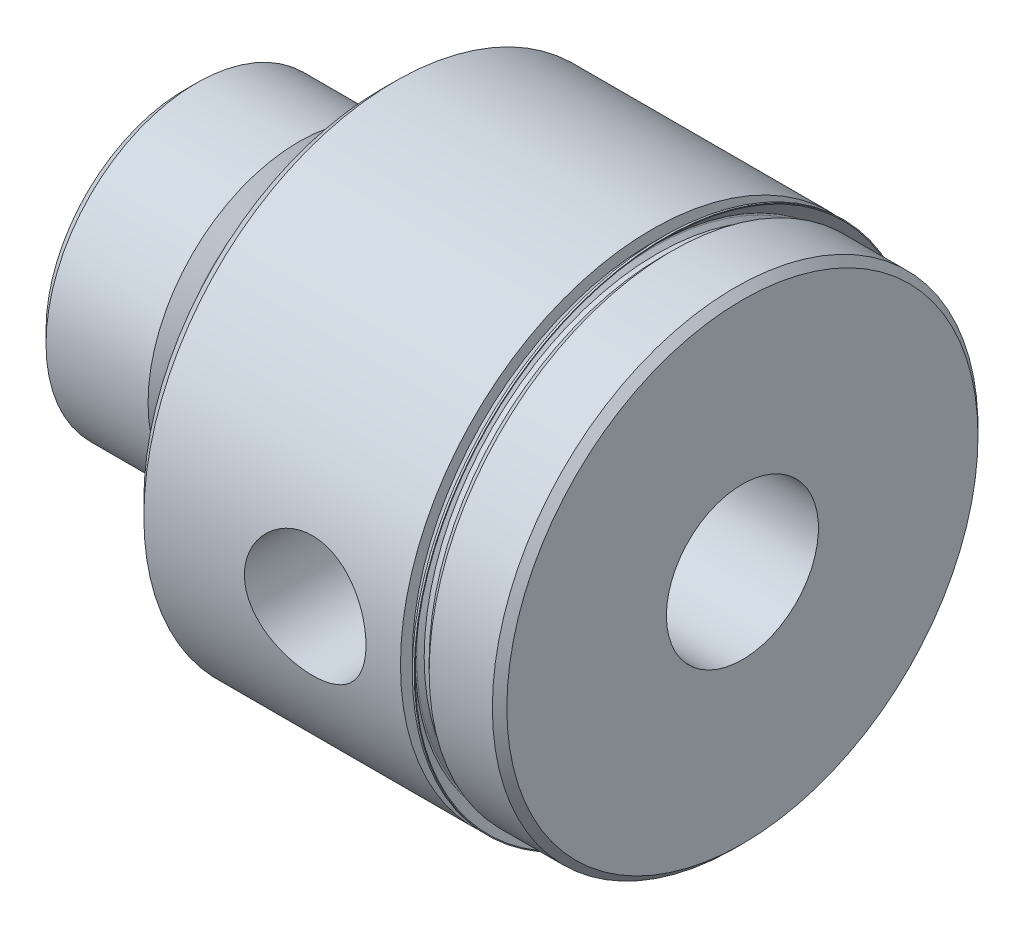
from build123d import *

# Parameters (mm, degrees)
HOLE1_D           = 16.0147
HOLE1_CSINK_D     = 17.5387
HOLE1_CSINK_ANGLE = 90


with BuildPart() as part:
    # Sketch1 → Revolve1 (revolve)
    with BuildSketch(Plane.XY):
        with BuildLine():
            Line((0, 0), (0, 14.61516))
            Line((0, 14.61516), (1.25984, 15.875))
            Line((1.25984, 15.875), (12.006992339, 15.875))
            Line((12.006992339, 15.875), (13.283429147, 14.641164804))
            ThreePointArc((13.283429147, 14.641164804), (13.72258185, 14.355749006), (14.2367, 14.25575))
            Line((14.2367, 14.25575), (16.1036, 14.25575))
            ThreePointArc((16.1036, 14.25575), (17.073467661, 14.657482339), (17.4752, 15.62735))
            Line((17.4752, 15.62735), (17.4752, 17.44345))
            Line((17.4752, 17.44345), (20.6502, 17.44345))
            Line((20.6502, 17.44345), (20.6502, 0))
            Line((20.6502, 0), (0, 0))
        make_face()
    revolve(axis=Axis((20.6502, 0, 0), (-1, 0, 0)))

    # Sketch2 → Revolve2 (revolve)
    with BuildSketch(Plane.XY):
        Polygon((20.6502, 0), (20.6502, 24.96185), (22.1742, 26.48585), (49.1998, 26.48585), (49.1998, 24.51735), (50.2539, 24.51735), (51.308, 25.57145), (57.9628, 25.57145), (58.7248, 24.80945), (58.7248, 0), align=None)
    revolve(axis=Axis((58.7248, 0, 0), (-1, 0, 0)))

    # Hole1 (through all)
    with Locations(Plane.ZY):
        with Locations((0, 0)):
            CounterSinkHole(HOLE1_D / 2, HOLE1_CSINK_D / 2, counter_sink_angle=HOLE1_CSINK_ANGLE)

    # Sketch5 → Cut-Revolve1 (revolve, cut)
    with BuildSketch(Plane(origin=(0, 0, 0), x_dir=(1, 0, 0), z_dir=(0, 1, 0))):
        Polygon((39.1668, 0), (42.3418, 0), (42.3418, -8.986753545), (45.108896455, -11.75385), (45.568822746, -26.48585), (39.1668, -26.48585), align=None)
    revolve(axis=Axis((39.1668, 0, 26.48585), (0, 0, -1)), mode=Mode.SUBTRACT)

    # Sketch6 → Revolve3 (revolve)
    with BuildSketch(Plane.XY):
        with BuildLine():
            Line((49.1998, 24.26335), (50.2539, 24.26335))
            Line((50.2539, 24.26335), (50.2539, 24.51735))
            Line((50.2539, 24.51735), (49.72685, 24.51735))
            Line((49.72685, 24.51735), (49.334816303, 24.909383697))
            ThreePointArc((49.334816303, 24.909383697), (49.297618864, 24.999186258), (49.334816303, 25.088988819))
            Line((49.334816303, 25.088988819), (50.647509288, 26.401681804))
            Line((50.647509288, 26.401681804), (50.647509288, 26.48585))
            Line((50.647509288, 26.48585), (50.444309288, 26.48585))
            Line((50.444309288, 26.48585), (49.1998, 25.241340712))
            Line((49.1998, 25.241340712), (49.1998, 24.26335))
        make_face()
    revolve(axis=Axis((50.2539, 0, 0), (-1, 0, 0)))


solid = part.part
